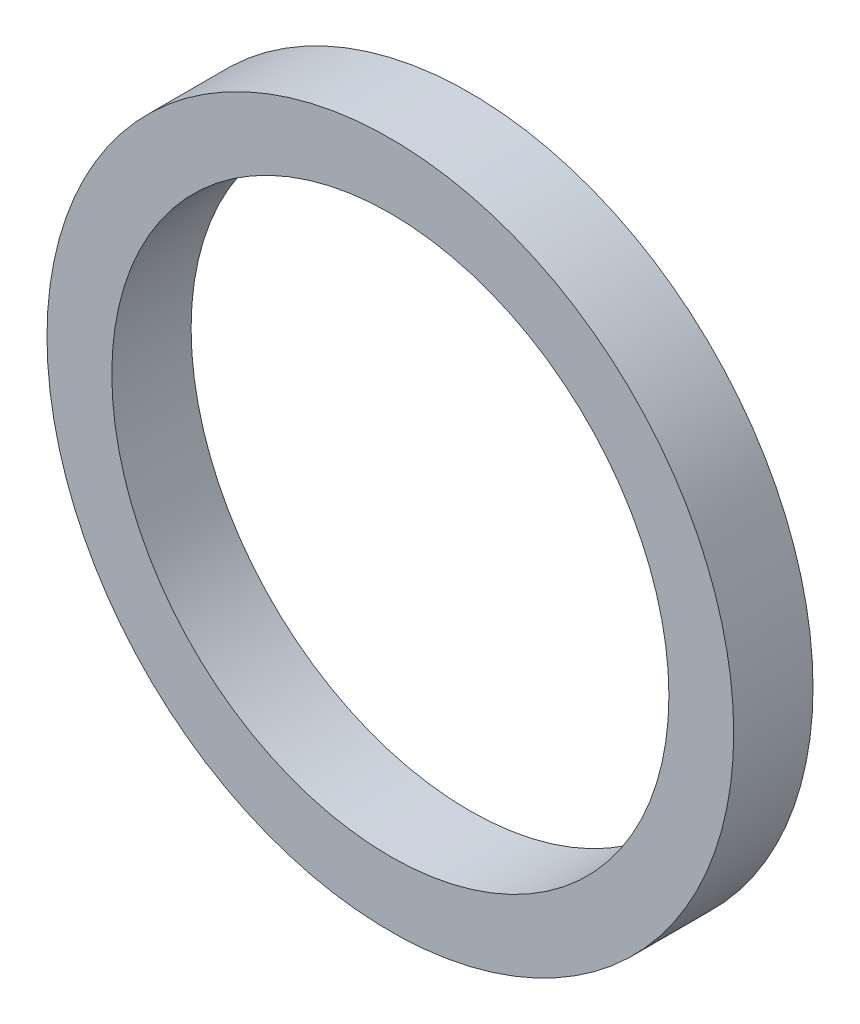
from build123d import *

# Parameters (mm, degrees)
SKETCH1_R           = 32.999888912
BOSS_EXTRUDE1_DEPTH = 7.62
SKETCH2_R           = 26.770142408
CUT_EXTRUDE1_DEPTH  = 7.62


with BuildPart() as part:
    # Sketch1 → Boss-Extrude1 (new body)
    with BuildSketch(Plane.XY):
        Circle(SKETCH1_R)
    extrude(amount=BOSS_EXTRUDE1_DEPTH)

    # Sketch2 → Cut-Extrude1 (cut)
    with BuildSketch(Plane.XY.offset(7.62)):
        Circle(SKETCH2_R)
    extrude(amount=-CUT_EXTRUDE1_DEPTH, mode=Mode.SUBTRACT)


solid = part.part
